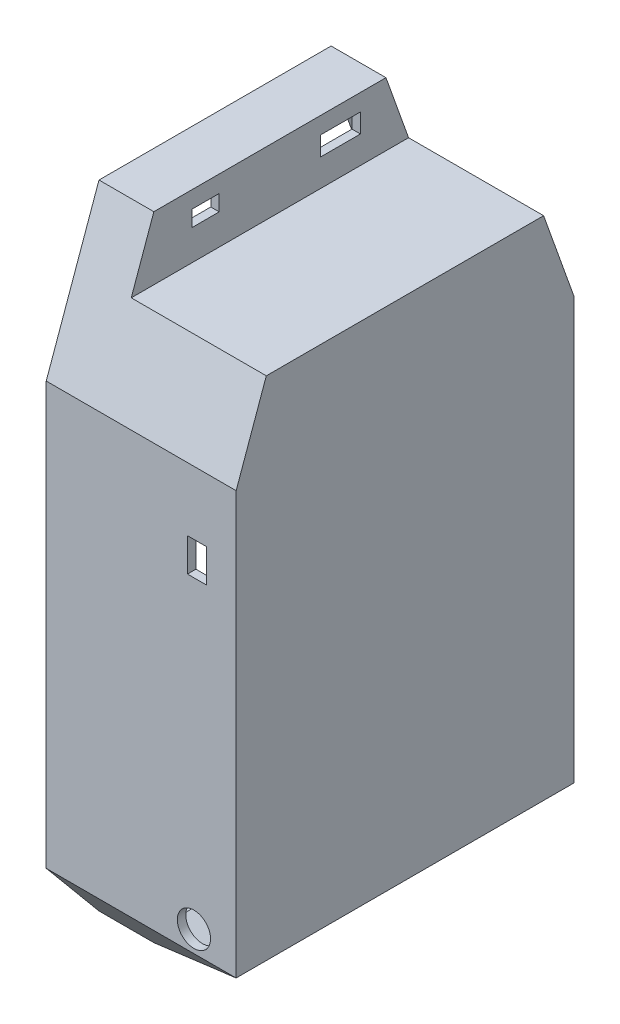
from build123d import *

# Parameters (mm, degrees)
BOSS_EXTRUDE2_DEPTH = 101.6
CUT_EXTRUDE1_DEPTH  = 58.15
SHELL1_T            = -2.54
SKETCH3_W           = 8.2
SKETCH3_H           = 4.8
SKETCH3_W_2         = 12
SKETCH3_H_2         = 5.75
CUT_EXTRUDE2_DEPTH  = 17.51
SKETCH4_W           = 5.75
SKETCH4_H           = 10
CUT_EXTRUDE3_DEPTH  = 27.94
SKETCH5_W           = 5.75
SKETCH5_H           = 12.75
CUT_EXTRUDE4_DEPTH  = 27.94
SKETCH6_R           = 5
CUT_EXTRUDE5_DEPTH  = 27.94


with BuildPart() as part:
    # Sketch1 → Boss-Extrude2 (new body)
    with BuildSketch(Plane.XY):
        Polygon((0, 0), (0, 190.5), (16.51, 190.5), (16.51, 171.45), (57.15, 171.45), (57.15, 19.05), (16.51, 0), align=None)
    extrude(amount=BOSS_EXTRUDE2_DEPTH)

    # Sketch2 → Cut-Extrude1 (cut, through all)
    with BuildSketch(Plane.ZY):
        Polygon((15.875, 190.5), (0, 146.05), (0, 190.5), align=None)
        Polygon((0, 19.05), (15.875, 0), (0, 0), align=None)
        Polygon((85.725, 0), (101.6, 19.05), (101.6, 0), align=None)
        Polygon((101.6, 146.05), (85.725, 190.5), (101.6, 190.5), align=None)
    extrude(amount=-CUT_EXTRUDE1_DEPTH, mode=Mode.SUBTRACT)

    # Shell1
    shell1_openings = [part.faces().sort_by_distance(p)[0] for p in [
        (0, 88.9, 50.8),
    ]]
    offset(amount=SHELL1_T, openings=shell1_openings, kind=Kind.INTERSECTION)

    # Sketch3 → Cut-Extrude2 (cut, through all)
    with BuildSketch(Plane(origin=(16.51, 0, 0), x_dir=(0, 0, -1), z_dir=(1, 0, 0))):
        with Locations((-70.147400598, 183.02)):
            Rectangle(SKETCH3_W, SKETCH3_H)
        with Locations((-29.56, 182.545)):
            Rectangle(SKETCH3_W_2, SKETCH3_H_2)
    extrude(amount=-CUT_EXTRUDE2_DEPTH, mode=Mode.SUBTRACT)

    # Sketch4 → Cut-Extrude3 (cut)
    with BuildSketch(Plane.XY.offset(101.6)):
        with Locations((45.385, 122)):
            Rectangle(SKETCH4_W, SKETCH4_H)
    extrude(amount=-CUT_EXTRUDE3_DEPTH, mode=Mode.SUBTRACT)

    # Sketch5 → Cut-Extrude4 (cut)
    with BuildSketch(Plane(origin=(0, 0, 0), x_dir=(-1, 0, 0), z_dir=(0, 0, -1))):
        with Locations((-45.385, 120.625)):
            Rectangle(SKETCH5_W, SKETCH5_H)
    extrude(amount=-CUT_EXTRUDE4_DEPTH, mode=Mode.SUBTRACT)

    # Sketch6 → Cut-Extrude5 (cut)
    with BuildSketch(Plane.XY.offset(101.6)):
        with Locations((44.45, 25.4)):
            Circle(SKETCH6_R)
    extrude(amount=-CUT_EXTRUDE5_DEPTH, mode=Mode.SUBTRACT)


solid = part.part
